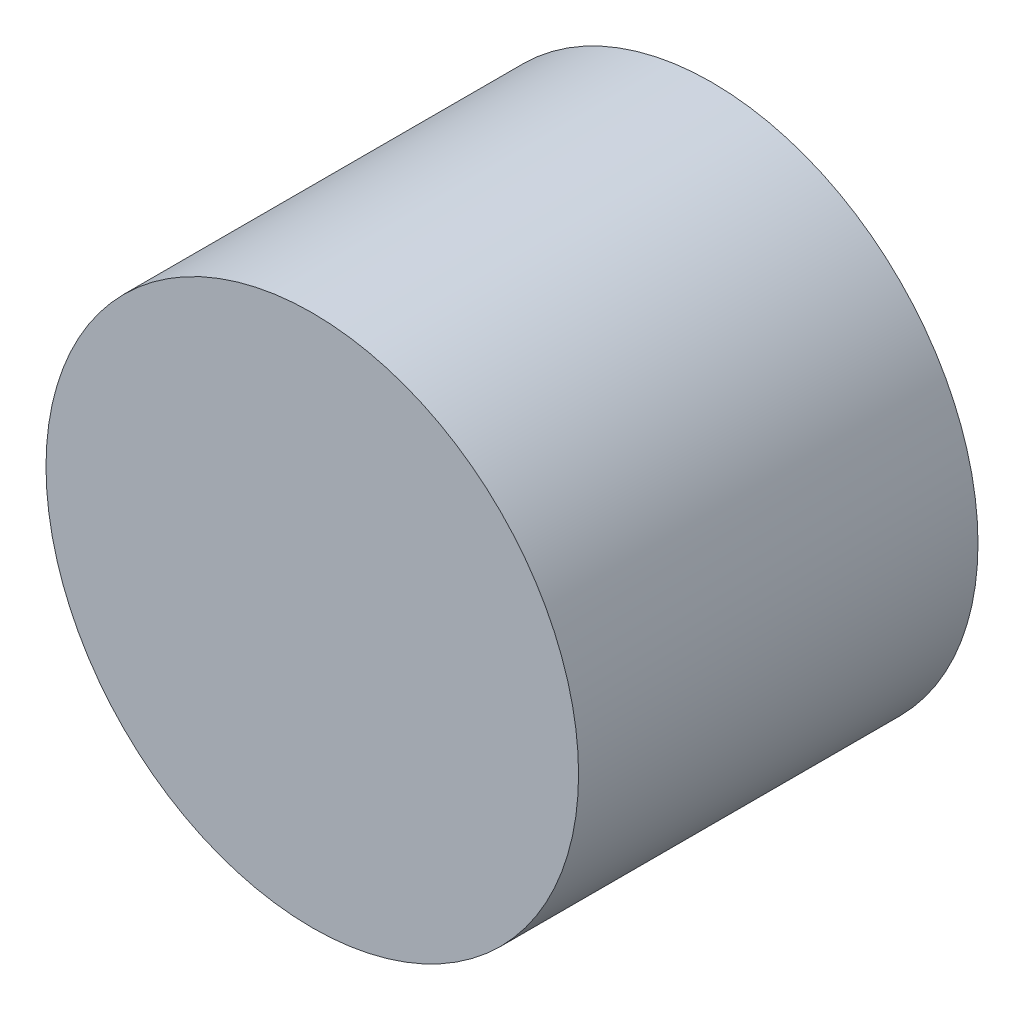
from build123d import *

# Parameters (mm, degrees)
SKETCH1_R           = 12.7
BOSS_EXTRUDE1_DEPTH = 19.05


with BuildPart() as part:
    # Sketch1 → Boss-Extrude1 (new body)
    with BuildSketch(Plane.XY):
        with Locations((0, -25.4)):
            Circle(SKETCH1_R)
    extrude(amount=BOSS_EXTRUDE1_DEPTH)


solid = part.part
